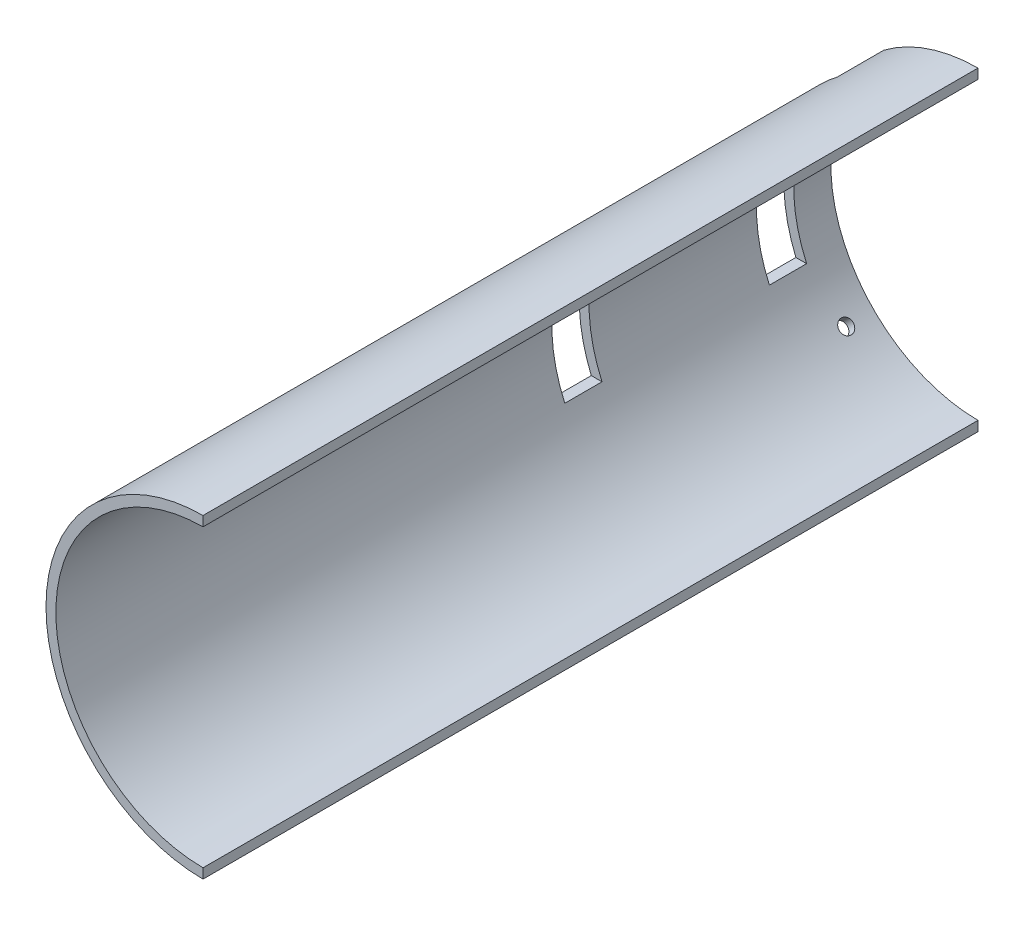
from build123d import *

# Parameters (mm, degrees)
BOSS_EXTRUDE1_DEPTH      = 250
M4_CLEARANCE_HOLE1_D     = 4.5
M4_CLEARANCE_HOLE1_DEPTH = 15
M4_CLEARANCE_HOLE1_TIP   = 1.351936393
M4_CLEARANCE_HOLE2_D     = 4.5
M4_CLEARANCE_HOLE2_DEPTH = 15
M4_CLEARANCE_HOLE2_TIP   = 1.351936393
SKETCH9_W                = 12
SKETCH9_H                = 39
CUT_EXTRUDE1_DEPTH       = 10
CUT_EXTRUDE2_DEPTH       = 15
CIRPATTERN1_COUNT        = 2
CIRPATTERN1_ANGLE        = 270
CUT_EXTRUDE4_DEPTH       = 261.117819555


with BuildPart() as part:
    # Sketch1 → Boss-Extrude1 (new body)
    with BuildSketch(Plane.XY):
        with BuildLine():
            Line((0, 50.8), (0, 47.62))
            ThreePointArc((0, 47.62), (-47.62, 0), (0, -47.62))
            Line((0, -47.62), (0, -50.8))
            ThreePointArc((0, -50.8), (-50.8, 0), (0, 50.8))
        make_face()
    extrude(amount=BOSS_EXTRUDE1_DEPTH)

    # M4 Clearance Hole1
    with Locations(Plane(origin=(-35.921024484, 35.921024484, 0), x_dir=(0, 0, -1), z_dir=(-0.707106781186549, 0.7071067811865461, 0))):
        with Locations((-9, 0)):
            Hole(M4_CLEARANCE_HOLE1_D / 2, depth=M4_CLEARANCE_HOLE1_DEPTH)
            with Locations((0, 0, -(M4_CLEARANCE_HOLE1_DEPTH + M4_CLEARANCE_HOLE1_TIP / 2))):  # 118° drill point
                Cone(0, M4_CLEARANCE_HOLE1_D / 2, M4_CLEARANCE_HOLE1_TIP, mode=Mode.SUBTRACT)

    # M4 Clearance Hole2
    with Locations(Plane(origin=(-35.921024484, -35.921024484, 0), x_dir=(0, 0, -1), z_dir=(-0.7071067811865588, -0.7071067811865362, 0))):
        with Locations((-9, 0)):
            Hole(M4_CLEARANCE_HOLE2_D / 2, depth=M4_CLEARANCE_HOLE2_DEPTH)
            with Locations((0, 0, -(M4_CLEARANCE_HOLE2_DEPTH + M4_CLEARANCE_HOLE2_TIP / 2))):  # 118° drill point
                Cone(0, M4_CLEARANCE_HOLE2_D / 2, M4_CLEARANCE_HOLE2_TIP, mode=Mode.SUBTRACT)

    # Sketch9 → Cut-Extrude1 (cut)
    with BuildSketch(Plane.ZY.offset(50.8)):
        with Locations((84, 0)):
            Rectangle(SKETCH9_W, SKETCH9_H)
        with Locations((18, 0)):
            Rectangle(SKETCH9_W, SKETCH9_H)
    extrude(amount=-CUT_EXTRUDE1_DEPTH, mode=Mode.SUBTRACT)

    # Sketch14 → Cut-Extrude2 (cut)
    with BuildSketch(Plane(origin=(0, 0, 0), x_dir=(-1, 0, 0), z_dir=(0, 0, -1))):
        with BuildLine():
            ThreePointArc((40.594896689, 30.540045233), (35.921024484, 35.921024484), (30.540045233, 40.594896689))
            Line((30.540045233, 40.594896689), (40.594896689, 30.540045233))
        make_face()
    cut_extrude2 = extrude(amount=-CUT_EXTRUDE2_DEPTH, mode=Mode.SUBTRACT)

    # CirPattern1: Cut-Extrude2 ×2 about axis
    cirpattern1_axis = Axis((0, 0, 250), (0, 0, -1))
    for i in range(1, CIRPATTERN1_COUNT):
        add(cut_extrude2.rotate(cirpattern1_axis, i * CIRPATTERN1_ANGLE / (CIRPATTERN1_COUNT - 1)), mode=Mode.SUBTRACT)

    # Sketch15 → Cut-Extrude4 (cut, through all)
    with BuildSketch(Plane(origin=(0, 0, 0), x_dir=(-1, 0, 0), z_dir=(0, 0, -1))):
        Polygon((0, 50.8), (0.15, 50.8), (0.15, -50.799778543), (0.15, -50.826071735), (0, -50.826071735), (0, -50.799778543), align=None)
    extrude(amount=-CUT_EXTRUDE4_DEPTH, mode=Mode.SUBTRACT)


solid = part.part
